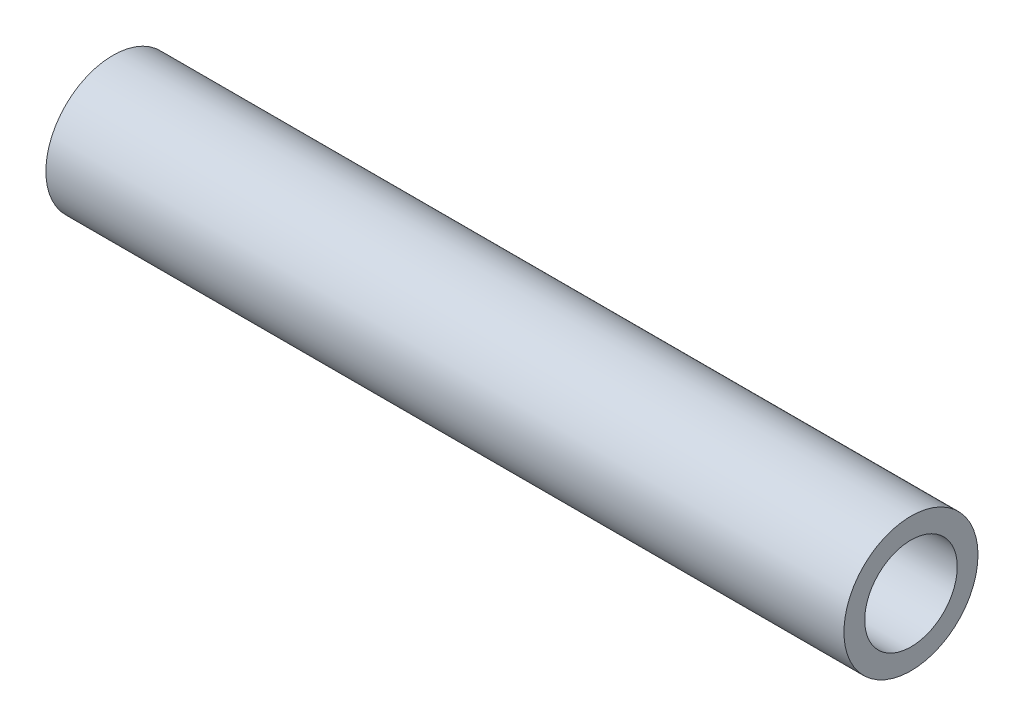
from build123d import *

# Parameters (mm, degrees)
SKETCH1_R           = 10.668
SKETCH1_R_2         = 7.366
BOSS_EXTRUDE1_DEPTH = 127


with BuildPart() as part:
    # Sketch1 → Boss-Extrude1 (new body)
    with BuildSketch(Plane(origin=(0, 0, 0), x_dir=(0, 0, -1), z_dir=(1, 0, 0))):
        Circle(SKETCH1_R)
        Circle(SKETCH1_R_2, mode=Mode.SUBTRACT)
    extrude(amount=-BOSS_EXTRUDE1_DEPTH)


solid = part.part
